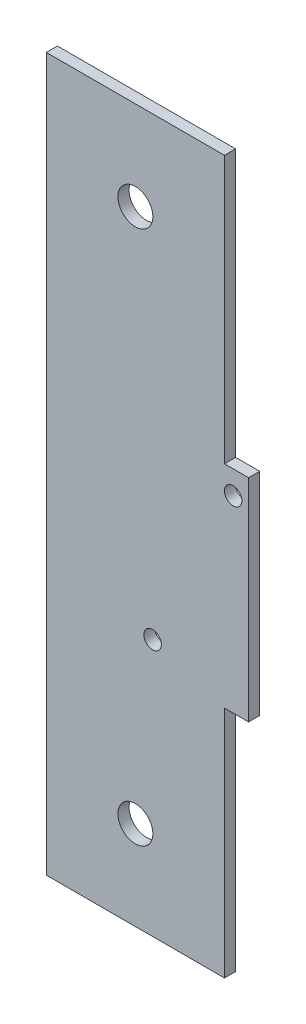
from build123d import *

# Parameters (mm, degrees)
SKETCH1_R           = 2.4892
SKETCH1_R_2         = 1.25
BOSS_EXTRUDE1_DEPTH = 1.5875


with BuildPart() as part:
    # Sketch1 → Boss-Extrude1 (new body)
    with BuildSketch(Plane.XY):
        Polygon((0, -50.8), (0, -152.4), (25.4, -152.4), (25.4, -119.0625), (28.837475462, -119.0625), (28.837475462, -88.9), (25.4, -88.9), (25.4, -50.8), align=None)
        with Locations((12.7, -63.5)):
            Circle(SKETCH1_R, mode=Mode.SUBTRACT)
        with Locations((12.7, -139.7)):
            Circle(SKETCH1_R, mode=Mode.SUBTRACT)
        with Locations((15.15518054, -115.738269016)):
            Circle(SKETCH1_R_2, mode=Mode.SUBTRACT)
        with Locations((26.638643662, -92.23018371)):
            Circle(SKETCH1_R_2, mode=Mode.SUBTRACT)
    extrude(amount=BOSS_EXTRUDE1_DEPTH)


solid = part.part
